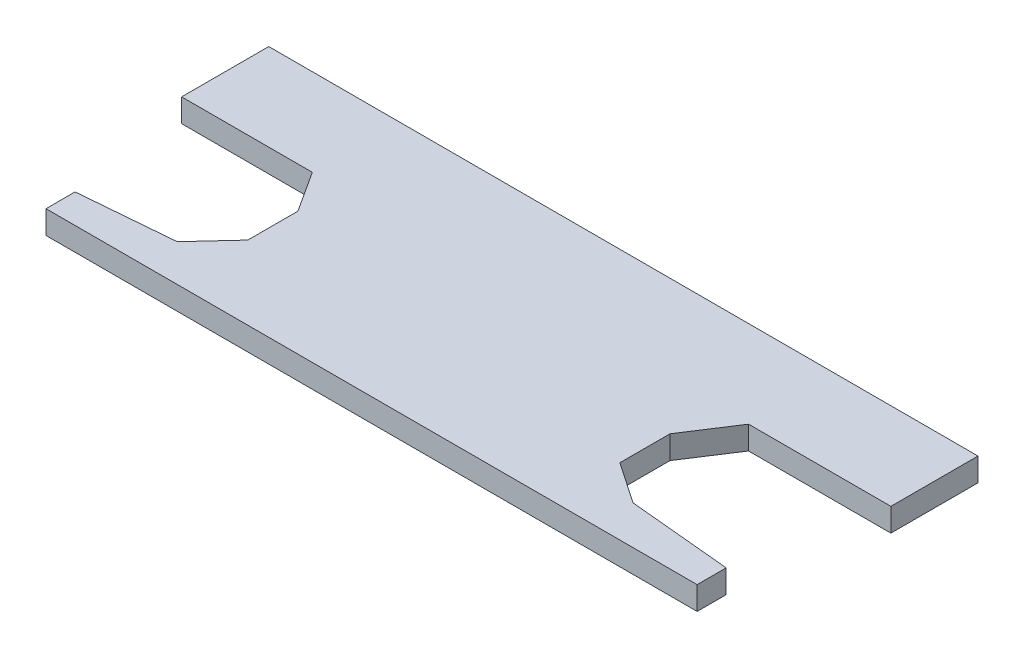
from build123d import *

# Parameters (mm, degrees)
SKETCH1_W         = 48.84
SKETCH1_H         = 17.34
MAIN_SQUARE_DEPTH = 1.6
SERVO_HOLES_DEPTH = 1.6


with BuildPart() as part:
    # Sketch1 → main square (new body)
    with BuildSketch(Plane(origin=(0, 0, 0), x_dir=(1, 0, 0), z_dir=(0, 1, 0))):
        with Locations((24.42, 8.67)):
            Rectangle(SKETCH1_W, SKETCH1_H)
    extrude(amount=MAIN_SQUARE_DEPTH)

    # Sketch2 → servo holes (cut)
    with BuildSketch(Plane(origin=(0, 1.6, 0), x_dir=(1, 0, 0), z_dir=(0, 1, 0))):
        Polygon((46.84, 2), (46.84, 0), (48.84, 0), (48.84, 11.34), (39.04, 11.34), (36.91, 8.061097745), (36.91, 4.611097745), (39.750024568, 2.67), align=None)
        Polygon((9, 11.34), (0, 11.34), (0, 0), (2, 0), (2, 2), (8.486484798, 2.55), (10.82, 5.07751), (10.82, 8.52751), align=None)
    extrude(amount=-SERVO_HOLES_DEPTH, mode=Mode.SUBTRACT)


solid = part.part
